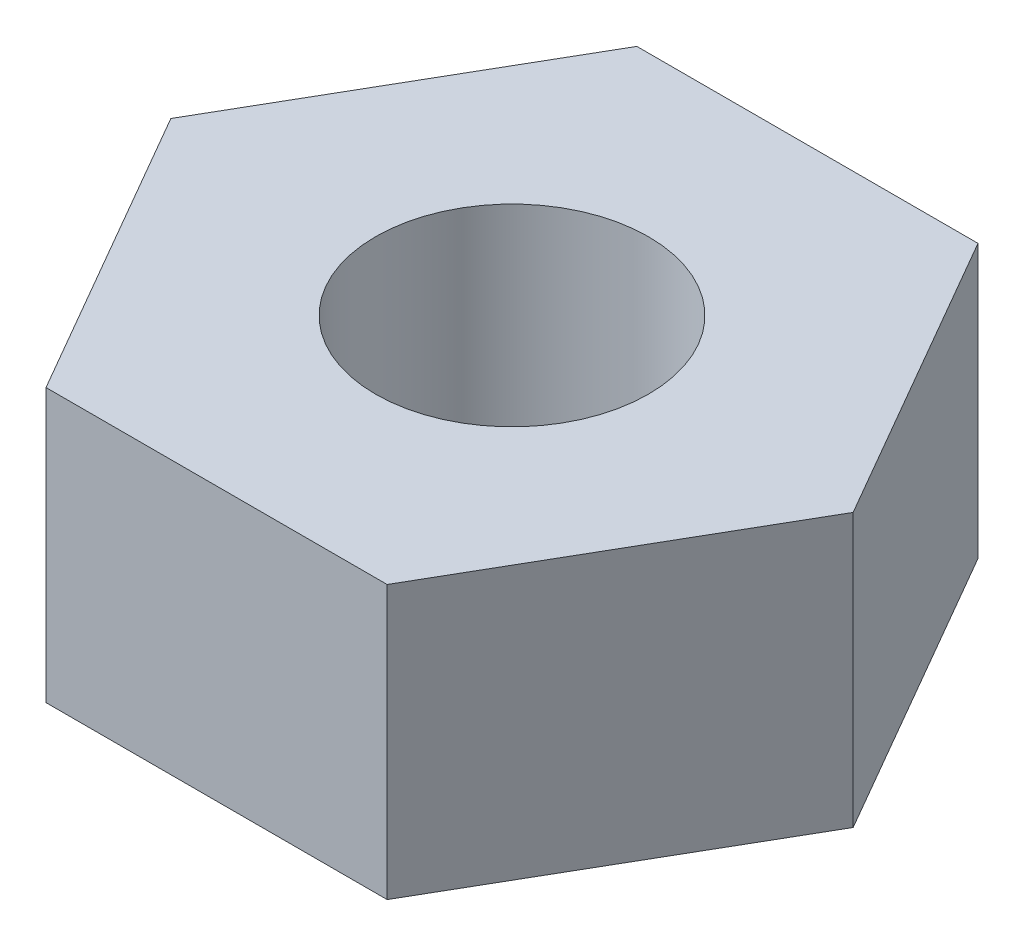
from build123d import *

# Parameters (mm, degrees)
CROQUIS1_R              = 2
SALIENTE_EXTRUIR1_DEPTH = 4


with BuildPart() as part:
    # Croquis1 → Saliente-Extruir1 (new body)
    with BuildSketch(Plane(origin=(0, 0, 0), x_dir=(1, 0, 0), z_dir=(0, 1, 0))):
        Polygon((5, 0), (2.5, 4.330127019), (-2.5, 4.330127019), (-5, 0), (-2.5, -4.330127019), (2.5, -4.330127019), align=None)
        Circle(CROQUIS1_R, mode=Mode.SUBTRACT)
    extrude(amount=SALIENTE_EXTRUIR1_DEPTH)


solid = part.part
